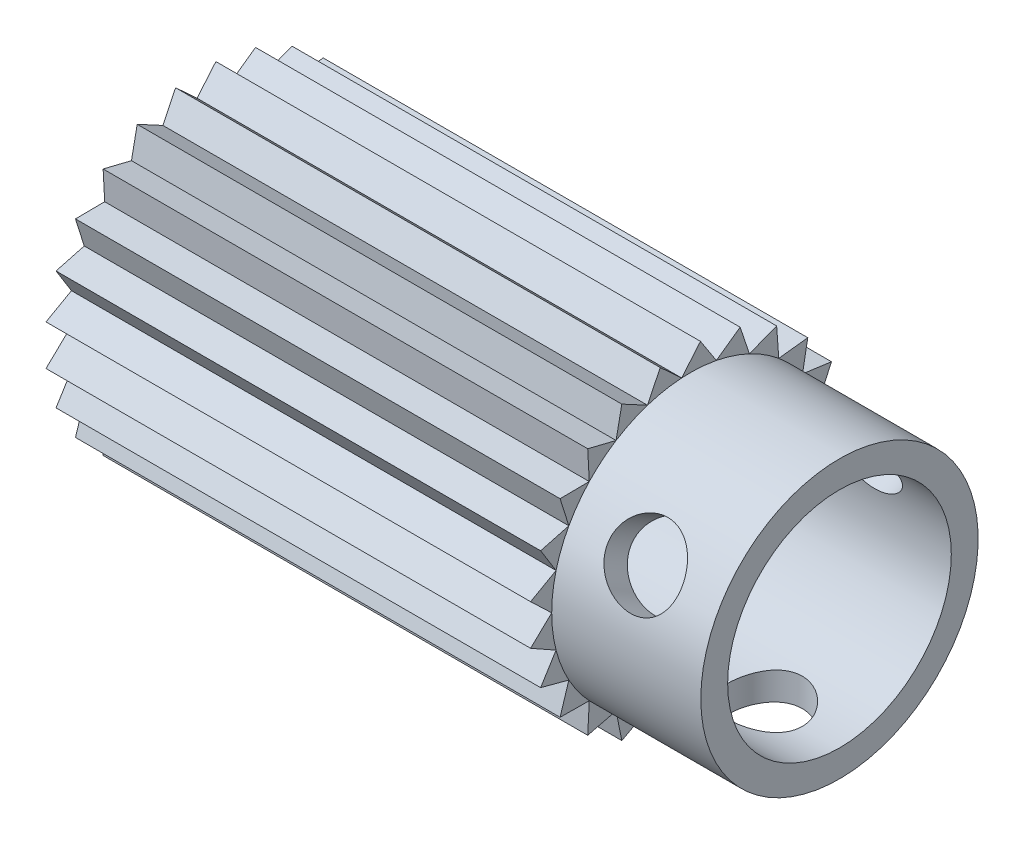
from build123d import *

# Parameters (mm, degrees)
SKETCH2_R          = 3.175
CUT_EXTRUDE1_DEPTH = 16.875
CIRPATTERN1_COUNT  = 3
SKETCH3_R          = 15.875
CUT_EXTRUDE2_DEPTH = 54.9750001


with BuildPart() as part:
    # Sketch1 → Revolve1 (revolve)
    with BuildSketch(Plane(origin=(0, 0, 0), x_dir=(1, 0, 0), z_dir=(0, 1, 0))):
        Polygon((-30.1625, -15.875), (-30.1625, -6.35), (-23.8125, -6.35), (-23.8125, -9.525), (23.8125, -9.525), (23.8125, -11.811), (11.1125, -11.811), (11.1125, -15.875), align=None)
    revolve(axis=Axis((-42.066572288, 0, 0), (1, 0, 0)))

    # Sketch2 → Cut-Extrude1 (cut, through all)
    with BuildSketch(Plane(origin=(0, 0, 0), x_dir=(1, 0, 0), z_dir=(0, 1, 0))):
        with Locations((17.4625, 0)):
            Circle(SKETCH2_R)
    cut_extrude1 = extrude(amount=-CUT_EXTRUDE1_DEPTH, mode=Mode.SUBTRACT)

    # CirPattern1: Cut-Extrude1 ×3 about axis
    cirpattern1_axis = Axis((-42.066572288, 0, 0), (1, 0, 0))
    for i in range(1, CIRPATTERN1_COUNT):
        add(cut_extrude1.rotate(cirpattern1_axis, i * 360 / CIRPATTERN1_COUNT), mode=Mode.SUBTRACT)

    # Sketch3 → Cut-Extrude2 (cut, through all)
    with BuildSketch(Plane.ZY.offset(30.1625)):
        Circle(SKETCH3_R)
        Polygon((13.607845243, 1.719070632), (11.811, 0), (13.607845243, -1.719070632), (11.439935716, -2.937276257), (12.75281428, -5.049196365), (10.350058198, -5.689992645), (11.096477095, -8.06206252), (8.609848458, -8.085185868), (8.742907443, -10.568359638), (6.328650275, -9.972357128), (5.839988763, -12.410607852), (3.649799721, -11.232928514), (2.570122111, -13.473051931), (0.741618826, -11.787693689), (-0.861234766, -13.688934607), (-2.213160707, -11.601794718), (-4.238477095, -13.044691178), (-5.028879213, -10.686912317), (-7.34940032, -11.580801826), (-7.528614743, -9.10053191), (-9.998533694, -9.389248105), (-9.555299721, -6.942331615), (-12.019422423, -6.607733394), (-10.981590075, -4.347919092), (-13.285086638, -3.411030492), (-11.717866737, -1.480310822), (-13.716, 0), (-11.717866737, 1.480310822), (-13.285086638, 3.411030492), (-10.981590075, 4.347919092), (-12.019422423, 6.607733394), (-9.555299721, 6.942331615), (-9.998533694, 9.389248105), (-7.528614743, 9.10053191), (-7.34940032, 11.580801826), (-5.028879213, 10.686912317), (-4.238477095, 13.044691178), (-2.213160707, 11.601794718), (-0.861234766, 13.688934607), (0.741618826, 11.787693689), (2.570122111, 13.473051931), (3.649799721, 11.232928514), (5.839988763, 12.410607852), (6.328650275, 9.972357128), (8.742907443, 10.568359638), (8.609848458, 8.085185868), (11.096477095, 8.06206252), (10.350058198, 5.689992645), (12.75281428, 5.049196365), (11.439935716, 2.937276257), align=None, mode=Mode.SUBTRACT)
    extrude(amount=-CUT_EXTRUDE2_DEPTH, mode=Mode.SUBTRACT)


solid = part.part
